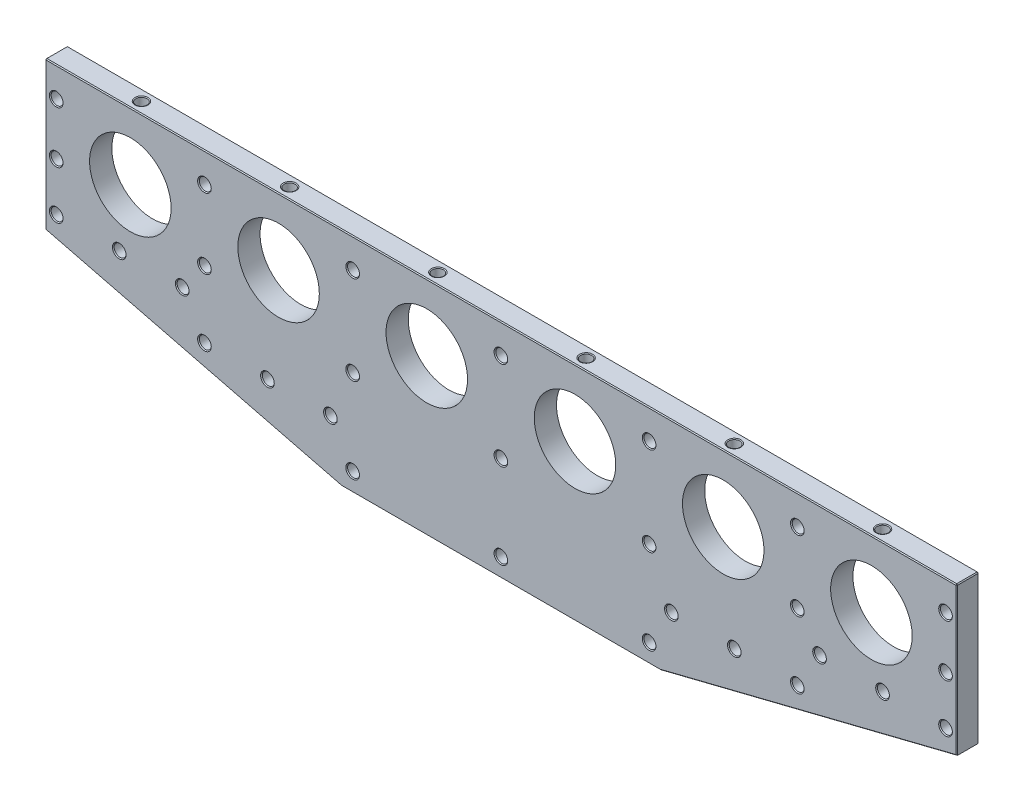
from build123d import *

# Parameters (mm, degrees)
SKETCH1_W                         = 781.05
SKETCH1_H                         = 190.5
BASE_EXTRUDE_DEPTH                = 9.525
CUT_EXTRUDE1_DEPTH                = 20.05
F_3_8_CLEARANCE_HOLE1_AT_2_COUNT  = 2
F_3_8_CLEARANCE_HOLE1_AT_2_PITCH  = 383.584153088
F_3_8_CLEARANCE_HOLE1_AT_3_COUNT  = 2
F_3_8_CLEARANCE_HOLE1_AT_3_PITCH  = 390.525
F_3_8_CLEARANCE_HOLE1_AT_4_COUNT  = 2
F_3_8_CLEARANCE_HOLE1_AT_4_PITCH  = 279.850630918
F_3_8_CLEARANCE_HOLE1_AT_5_COUNT  = 2
F_3_8_CLEARANCE_HOLE1_AT_5_PITCH  = 261.065328271
F_3_8_CLEARANCE_HOLE1_AT_6_COUNT  = 2
F_3_8_CLEARANCE_HOLE1_AT_6_PITCH  = 254
F_3_8_CLEARANCE_HOLE1_AT_7_COUNT  = 2
F_3_8_CLEARANCE_HOLE1_AT_7_PITCH  = 127
F_3_8_CLEARANCE_HOLE1_AT_8_COUNT  = 2
F_3_8_CLEARANCE_HOLE1_AT_8_PITCH  = 148.106178129
F_3_8_CLEARANCE_HOLE1_AT_9_COUNT  = 2
F_3_8_CLEARANCE_HOLE1_AT_9_PITCH  = 195.951781377
F_3_8_CLEARANCE_HOLE1_AT_10_COUNT = 2
F_3_8_CLEARANCE_HOLE1_AT_10_PITCH = 149.225
F_3_8_CLEARANCE_HOLE1_AT_11_COUNT = 2
F_3_8_CLEARANCE_HOLE1_AT_11_PITCH = 76.2
F_3_8_CLEARANCE_HOLE1_AT_12_COUNT = 2
F_3_8_CLEARANCE_HOLE1_AT_12_PITCH = 195.951781377
F_3_8_CLEARANCE_HOLE1_AT_13_COUNT = 2
F_3_8_CLEARANCE_HOLE1_AT_13_PITCH = 148.106178129
F_3_8_CLEARANCE_HOLE1_AT_14_COUNT = 2
F_3_8_CLEARANCE_HOLE1_AT_14_PITCH = 127
F_3_8_CLEARANCE_HOLE1_AT_15_COUNT = 2
F_3_8_CLEARANCE_HOLE1_AT_15_PITCH = 254
F_3_8_CLEARANCE_HOLE1_AT_16_COUNT = 2
F_3_8_CLEARANCE_HOLE1_AT_16_PITCH = 261.065328271
F_3_8_CLEARANCE_HOLE1_AT_17_COUNT = 2
F_3_8_CLEARANCE_HOLE1_AT_17_PITCH = 279.850630918
F_3_8_CLEARANCE_HOLE1_AT_18_COUNT = 2
F_3_8_CLEARANCE_HOLE1_AT_18_PITCH = 390.525
F_3_8_CLEARANCE_HOLE1_AT_19_COUNT = 2
F_3_8_CLEARANCE_HOLE1_AT_19_PITCH = 383.584153088
F_3_8_CLEARANCE_HOLE1_AT_20_COUNT = 2
F_3_8_CLEARANCE_HOLE1_AT_20_PITCH = 381
F_3_8_CLEARANCE_HOLE1_AT_21_COUNT = 2
F_3_8_CLEARANCE_HOLE1_AT_21_PITCH = 338.074143125
F_3_8_CLEARANCE_HOLE1_AT_22_COUNT = 2
F_3_8_CLEARANCE_HOLE1_AT_22_PITCH = 286.19063249
F_3_8_CLEARANCE_HOLE1_AT_23_COUNT = 2
F_3_8_CLEARANCE_HOLE1_AT_23_PITCH = 231.970636612
F_3_8_CLEARANCE_HOLE1_AT_24_COUNT = 2
F_3_8_CLEARANCE_HOLE1_AT_24_PITCH = 187.432596218
F_3_8_CLEARANCE_HOLE1_AT_25_COUNT = 2
F_3_8_CLEARANCE_HOLE1_AT_25_PITCH = 231.970636612
F_3_8_CLEARANCE_HOLE1_AT_26_COUNT = 2
F_3_8_CLEARANCE_HOLE1_AT_26_PITCH = 187.432596218
F_3_8_CLEARANCE_HOLE1_AT_27_COUNT = 2
F_3_8_CLEARANCE_HOLE1_AT_27_PITCH = 338.074143125
F_3_8_CLEARANCE_HOLE1_AT_28_COUNT = 2
F_3_8_CLEARANCE_HOLE1_AT_28_PITCH = 286.19063249
F_3_8_CLEARANCE_HOLE1_AT_29_COUNT = 2
F_3_8_CLEARANCE_HOLE1_AT_29_PITCH = 381
LPATTERN1_COUNT                   = 4
LPATTERN1_PITCH                   = 127
LPATTERN1_COL_COUNT               = 3
LPATTERN1_COL_PITCH               = 127
LARGE_VENT_HOLE_D                 = 69.85
CHAMFER1_SIZE                     = 0.762


with BuildPart() as part:
    # Sketch1 → Base-Extrude (new body, symmetric)
    with BuildSketch(Plane.XY):
        Rectangle(SKETCH1_W, SKETCH1_H)
    extrude(amount=BASE_EXTRUDE_DEPTH, both=True)

    # Sketch2 → Cut-Extrude1 (cut, through all)
    with BuildSketch(Plane.XY.offset(9.525)):
        Polygon((136.525, -95.25), (390.525, -31.75), (390.525, -95.25), align=None)
        Polygon((-136.525, -95.25), (-390.525, -95.25), (-390.525, -31.75), align=None)
    extrude(amount=-CUT_EXTRUDE1_DEPTH, mode=Mode.SUBTRACT)

    # Sketch3 → 3_8 Clearance Hole1 (revolve, cut)
    with BuildSketch(Plane(origin=(0, 69.85, 9.525), x_dir=(0, -1, 0), z_dir=(1, 0, 0))):
        Polygon((0, 0), (0, 19.05), (5.842, 19.05), (5.15874, 18.263999282), (5.15874, 0.786000718), (5.842, 0), align=None)
    f_3_8_clearance_hole1 = revolve(axis=Axis((0, 69.85, 15.875), (0, 0, -1)), mode=Mode.SUBTRACT)

    # 3_8 Clearance Hole1 at 2: 3_8 Clearance Hole1 ×2
    with Locations(*[Vector(0.993263139, -0.1158807, 0) * (i * F_3_8_CLEARANCE_HOLE1_AT_2_PITCH) for i in range(1, F_3_8_CLEARANCE_HOLE1_AT_2_COUNT)]):
        add(f_3_8_clearance_hole1, mode=Mode.SUBTRACT)

    # 3_8 Clearance Hole1 at 3: 3_8 Clearance Hole1 ×2
    with Locations(*[Vector(0.975609756, -0.219512195, 0) * (i * F_3_8_CLEARANCE_HOLE1_AT_3_PITCH) for i in range(1, F_3_8_CLEARANCE_HOLE1_AT_3_COUNT)]):
        add(f_3_8_clearance_hole1, mode=Mode.SUBTRACT)

    # 3_8 Clearance Hole1 at 4: 3_8 Clearance Hole1 ×2
    with Locations(*[Vector(0.907627041, -0.419777506, 0) * (i * F_3_8_CLEARANCE_HOLE1_AT_4_PITCH) for i in range(1, F_3_8_CLEARANCE_HOLE1_AT_4_COUNT)]):
        add(f_3_8_clearance_hole1, mode=Mode.SUBTRACT)

    # 3_8 Clearance Hole1 at 5: 3_8 Clearance Hole1 ×2
    with Locations(*[Vector(0.972936551, -0.231072431, 0) * (i * F_3_8_CLEARANCE_HOLE1_AT_5_PITCH) for i in range(1, F_3_8_CLEARANCE_HOLE1_AT_5_COUNT)]):
        add(f_3_8_clearance_hole1, mode=Mode.SUBTRACT)

    # 3_8 Clearance Hole1 at 6: 3_8 Clearance Hole1 ×2
    with Locations(*[(i * F_3_8_CLEARANCE_HOLE1_AT_6_PITCH, 0, 0) for i in range(1, F_3_8_CLEARANCE_HOLE1_AT_6_COUNT)]):
        add(f_3_8_clearance_hole1, mode=Mode.SUBTRACT)

    # 3_8 Clearance Hole1 at 7: 3_8 Clearance Hole1 ×2
    with Locations(*[(i * F_3_8_CLEARANCE_HOLE1_AT_7_PITCH, 0, 0) for i in range(1, F_3_8_CLEARANCE_HOLE1_AT_7_COUNT)]):
        add(f_3_8_clearance_hole1, mode=Mode.SUBTRACT)

    # 3_8 Clearance Hole1 at 8: 3_8 Clearance Hole1 ×2
    with Locations(*[Vector(0.857492926, -0.514495755, 0) * (i * F_3_8_CLEARANCE_HOLE1_AT_8_PITCH) for i in range(1, F_3_8_CLEARANCE_HOLE1_AT_8_COUNT)]):
        add(f_3_8_clearance_hole1, mode=Mode.SUBTRACT)

    # 3_8 Clearance Hole1 at 9: 3_8 Clearance Hole1 ×2
    with Locations(*[Vector(0.64811863, -0.76153939, 0) * (i * F_3_8_CLEARANCE_HOLE1_AT_9_PITCH) for i in range(1, F_3_8_CLEARANCE_HOLE1_AT_9_COUNT)]):
        add(f_3_8_clearance_hole1, mode=Mode.SUBTRACT)

    # 3_8 Clearance Hole1 at 10: 3_8 Clearance Hole1 ×2
    with Locations(*[(0, -i * F_3_8_CLEARANCE_HOLE1_AT_10_PITCH, 0) for i in range(1, F_3_8_CLEARANCE_HOLE1_AT_10_COUNT)]):
        add(f_3_8_clearance_hole1, mode=Mode.SUBTRACT)

    # 3_8 Clearance Hole1 at 11: 3_8 Clearance Hole1 ×2
    with Locations(*[(0, -i * F_3_8_CLEARANCE_HOLE1_AT_11_PITCH, 0) for i in range(1, F_3_8_CLEARANCE_HOLE1_AT_11_COUNT)]):
        add(f_3_8_clearance_hole1, mode=Mode.SUBTRACT)

    # 3_8 Clearance Hole1 at 12: 3_8 Clearance Hole1 ×2
    with Locations(*[Vector(-0.64811863, -0.76153939, 0) * (i * F_3_8_CLEARANCE_HOLE1_AT_12_PITCH) for i in range(1, F_3_8_CLEARANCE_HOLE1_AT_12_COUNT)]):
        add(f_3_8_clearance_hole1, mode=Mode.SUBTRACT)

    # 3_8 Clearance Hole1 at 13: 3_8 Clearance Hole1 ×2
    with Locations(*[Vector(-0.857492926, -0.514495755, 0) * (i * F_3_8_CLEARANCE_HOLE1_AT_13_PITCH) for i in range(1, F_3_8_CLEARANCE_HOLE1_AT_13_COUNT)]):
        add(f_3_8_clearance_hole1, mode=Mode.SUBTRACT)

    # 3_8 Clearance Hole1 at 14: 3_8 Clearance Hole1 ×2
    with Locations(*[(-i * F_3_8_CLEARANCE_HOLE1_AT_14_PITCH, 0, 0) for i in range(1, F_3_8_CLEARANCE_HOLE1_AT_14_COUNT)]):
        add(f_3_8_clearance_hole1, mode=Mode.SUBTRACT)

    # 3_8 Clearance Hole1 at 15: 3_8 Clearance Hole1 ×2
    with Locations(*[(-i * F_3_8_CLEARANCE_HOLE1_AT_15_PITCH, 0, 0) for i in range(1, F_3_8_CLEARANCE_HOLE1_AT_15_COUNT)]):
        add(f_3_8_clearance_hole1, mode=Mode.SUBTRACT)

    # 3_8 Clearance Hole1 at 16: 3_8 Clearance Hole1 ×2
    with Locations(*[Vector(-0.972936551, -0.231072431, 0) * (i * F_3_8_CLEARANCE_HOLE1_AT_16_PITCH) for i in range(1, F_3_8_CLEARANCE_HOLE1_AT_16_COUNT)]):
        add(f_3_8_clearance_hole1, mode=Mode.SUBTRACT)

    # 3_8 Clearance Hole1 at 17: 3_8 Clearance Hole1 ×2
    with Locations(*[Vector(-0.907627041, -0.419777506, 0) * (i * F_3_8_CLEARANCE_HOLE1_AT_17_PITCH) for i in range(1, F_3_8_CLEARANCE_HOLE1_AT_17_COUNT)]):
        add(f_3_8_clearance_hole1, mode=Mode.SUBTRACT)

    # 3_8 Clearance Hole1 at 18: 3_8 Clearance Hole1 ×2
    with Locations(*[Vector(-0.975609756, -0.219512195, 0) * (i * F_3_8_CLEARANCE_HOLE1_AT_18_PITCH) for i in range(1, F_3_8_CLEARANCE_HOLE1_AT_18_COUNT)]):
        add(f_3_8_clearance_hole1, mode=Mode.SUBTRACT)

    # 3_8 Clearance Hole1 at 19: 3_8 Clearance Hole1 ×2
    with Locations(*[Vector(-0.993263139, -0.1158807, 0) * (i * F_3_8_CLEARANCE_HOLE1_AT_19_PITCH) for i in range(1, F_3_8_CLEARANCE_HOLE1_AT_19_COUNT)]):
        add(f_3_8_clearance_hole1, mode=Mode.SUBTRACT)

    # 3_8 Clearance Hole1 at 20: 3_8 Clearance Hole1 ×2
    with Locations(*[(-i * F_3_8_CLEARANCE_HOLE1_AT_20_PITCH, 0, 0) for i in range(1, F_3_8_CLEARANCE_HOLE1_AT_20_COUNT)]):
        add(f_3_8_clearance_hole1, mode=Mode.SUBTRACT)

    # 3_8 Clearance Hole1 at 21: 3_8 Clearance Hole1 ×2
    with Locations(*[Vector(-0.967317397, -0.253568638, 0) * (i * F_3_8_CLEARANCE_HOLE1_AT_21_PITCH) for i in range(1, F_3_8_CLEARANCE_HOLE1_AT_21_COUNT)]):
        add(f_3_8_clearance_hole1, mode=Mode.SUBTRACT)

    # 3_8 Clearance Hole1 at 22: 3_8 Clearance Hole1 ×2
    with Locations(*[Vector(-0.954084338, -0.299538106, 0) * (i * F_3_8_CLEARANCE_HOLE1_AT_22_PITCH) for i in range(1, F_3_8_CLEARANCE_HOLE1_AT_22_COUNT)]):
        add(f_3_8_clearance_hole1, mode=Mode.SUBTRACT)

    # 3_8 Clearance Hole1 at 23: 3_8 Clearance Hole1 ×2
    with Locations(*[Vector(-0.86228586, -0.506421855, 0) * (i * F_3_8_CLEARANCE_HOLE1_AT_23_PITCH) for i in range(1, F_3_8_CLEARANCE_HOLE1_AT_23_COUNT)]):
        add(f_3_8_clearance_hole1, mode=Mode.SUBTRACT)

    # 3_8 Clearance Hole1 at 24: 3_8 Clearance Hole1 ×2
    with Locations(*[Vector(-0.77921345, -0.626758645, 0) * (i * F_3_8_CLEARANCE_HOLE1_AT_24_PITCH) for i in range(1, F_3_8_CLEARANCE_HOLE1_AT_24_COUNT)]):
        add(f_3_8_clearance_hole1, mode=Mode.SUBTRACT)

    # 3_8 Clearance Hole1 at 25: 3_8 Clearance Hole1 ×2
    with Locations(*[Vector(0.86228586, -0.506421855, 0) * (i * F_3_8_CLEARANCE_HOLE1_AT_25_PITCH) for i in range(1, F_3_8_CLEARANCE_HOLE1_AT_25_COUNT)]):
        add(f_3_8_clearance_hole1, mode=Mode.SUBTRACT)

    # 3_8 Clearance Hole1 at 26: 3_8 Clearance Hole1 ×2
    with Locations(*[Vector(0.77921345, -0.626758645, 0) * (i * F_3_8_CLEARANCE_HOLE1_AT_26_PITCH) for i in range(1, F_3_8_CLEARANCE_HOLE1_AT_26_COUNT)]):
        add(f_3_8_clearance_hole1, mode=Mode.SUBTRACT)

    # 3_8 Clearance Hole1 at 27: 3_8 Clearance Hole1 ×2
    with Locations(*[Vector(0.967317397, -0.253568638, 0) * (i * F_3_8_CLEARANCE_HOLE1_AT_27_PITCH) for i in range(1, F_3_8_CLEARANCE_HOLE1_AT_27_COUNT)]):
        add(f_3_8_clearance_hole1, mode=Mode.SUBTRACT)

    # 3_8 Clearance Hole1 at 28: 3_8 Clearance Hole1 ×2
    with Locations(*[Vector(0.954084338, -0.299538106, 0) * (i * F_3_8_CLEARANCE_HOLE1_AT_28_PITCH) for i in range(1, F_3_8_CLEARANCE_HOLE1_AT_28_COUNT)]):
        add(f_3_8_clearance_hole1, mode=Mode.SUBTRACT)

    # 3_8 Clearance Hole1 at 29: 3_8 Clearance Hole1 ×2
    with Locations(*[(i * F_3_8_CLEARANCE_HOLE1_AT_29_PITCH, 0, 0) for i in range(1, F_3_8_CLEARANCE_HOLE1_AT_29_COUNT)]):
        add(f_3_8_clearance_hole1, mode=Mode.SUBTRACT)

    # Sketch7 → 3_8-16 Tapped Hole1 (revolve, cut)
    with BuildSketch(Plane(origin=(-63.5, 95.25, 0), x_dir=(0, 0, 1), z_dir=(1, 0, 0))):
        Polygon((0, 0), (0, 26.209865582), (3.96875, 23.8252), (3.96875, 19.05), (4.7625, 19.05), (4.7625, 0.476602647), (5.588, 0), align=None)
    f_3_8_16_tapped_hole1 = revolve(axis=Axis((-63.5, 101.6, 0), (0, -1, 0)), mode=Mode.SUBTRACT)

    # LPattern1: 3_8-16 Tapped Hole1 ×4
    with Locations(*[(i * LPATTERN1_PITCH, 0, 0) for i in range(1, LPATTERN1_COUNT)]):
        add(f_3_8_16_tapped_hole1, mode=Mode.SUBTRACT)

    # LPattern1 col: 3_8-16 Tapped Hole1 ×3
    with Locations(*[(-i * LPATTERN1_COL_PITCH, 0, 0) for i in range(1, LPATTERN1_COL_COUNT)]):
        add(f_3_8_16_tapped_hole1, mode=Mode.SUBTRACT)

    # Large Vent Hole (through all)
    with Locations(Plane.XY.offset(9.525)):
        with Locations((317.5, 38.1), (190.5, 38.1), (63.5, 38.1), (-63.5, 38.1), (-190.5, 38.1), (-317.5, 38.1)):
            Hole(LARGE_VENT_HOLE_D / 2)

    # Chamfer1
    chamfer1_edges = [part.edges().sort_by_distance(p)[0] for p in [
        (390.525, 31.75, -9.525),
        (0, 95.25, 9.525),
        (390.525, 31.75, 9.525),
        (263.525, -63.5, -9.525),
        (263.525, -63.5, 9.525),
        (0, -95.25, -9.525),
        (0, -95.25, 9.525),
        (-263.525, -63.5, -9.525),
        (-263.525, -63.5, 9.525),
        (-390.525, 31.75, 9.525),
        (0, 95.25, -9.525),
        (-390.525, 31.75, -9.525),
        (-390.525, 95.25, 0),
        (390.525, 95.25, 0),
    ]]
    chamfer(chamfer1_edges, length=CHAMFER1_SIZE)


solid = part.part
